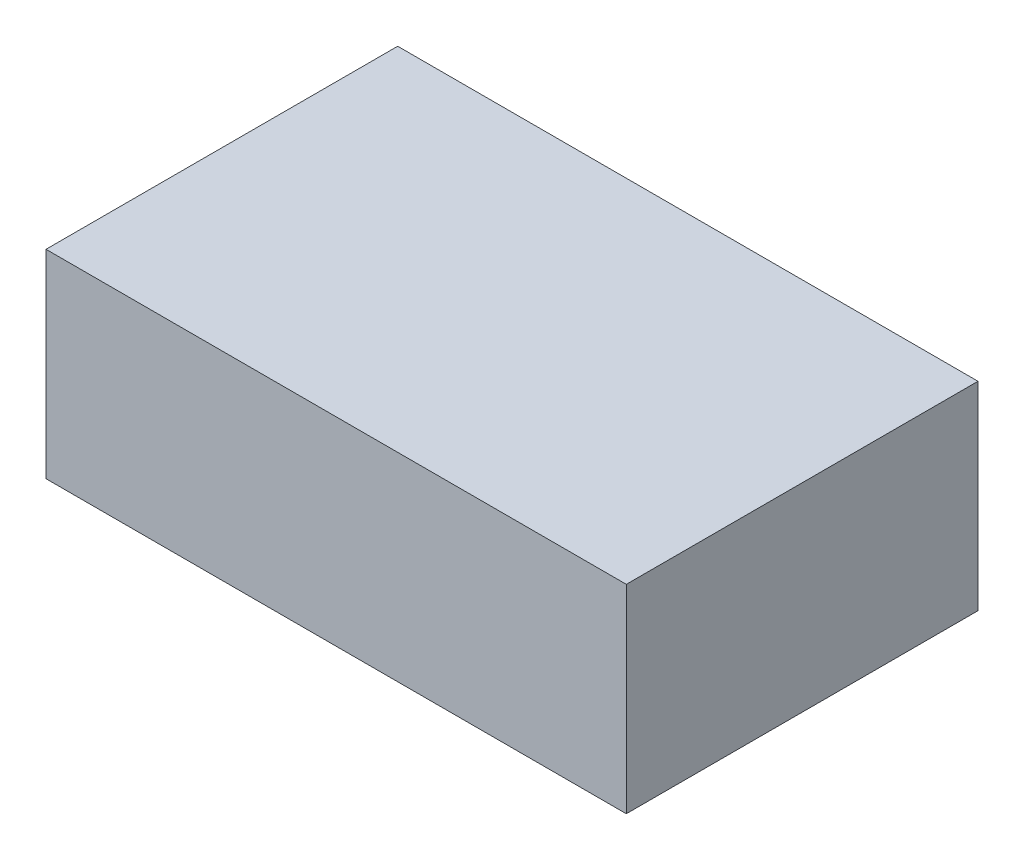
from build123d import *

# Parameters (mm, degrees)
SKETCH1_W           = 33
SKETCH1_H           = 20
BOSS_EXTRUDE1_DEPTH = 5.65


with BuildPart() as part:
    # Sketch1 → Boss-Extrude1 (new body, symmetric)
    with BuildSketch(Plane(origin=(0, 0, 0), x_dir=(1, 0, 0), z_dir=(0, 1, 0))):
        Rectangle(SKETCH1_W, SKETCH1_H)
    extrude(amount=BOSS_EXTRUDE1_DEPTH, both=True)


solid = part.part
